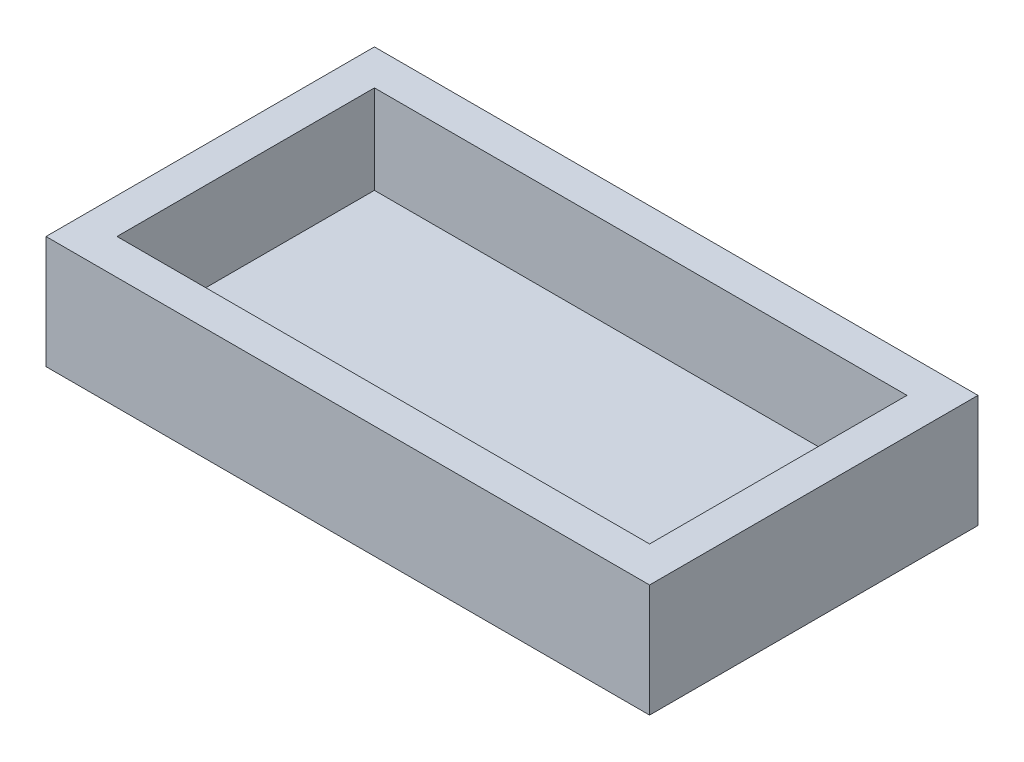
from build123d import *

# Parameters (mm, degrees)
SKETCH1_W           = 34
SKETCH1_H           = 18.5
SKETCH1_W_2         = 30
SKETCH1_H_2         = 14.5
BOSS_EXTRUDE1_DEPTH = 6.35
SKETCH2_W           = 30
SKETCH2_H           = 14.5
BOSS_EXTRUDE3_DEPTH = 1.35


with BuildPart() as part:
    # Sketch1 → Boss-Extrude1 (new body)
    with BuildSketch(Plane(origin=(0, 0, 0), x_dir=(1, 0, 0), z_dir=(0, 1, 0))):
        with Locations((15, 7.25)):
            Rectangle(SKETCH1_W, SKETCH1_H)
        with Locations((15, 7.25)):
            Rectangle(SKETCH1_W_2, SKETCH1_H_2, mode=Mode.SUBTRACT)
    extrude(amount=BOSS_EXTRUDE1_DEPTH)

    # Sketch2 → Boss-Extrude3 (add)
    with BuildSketch(Plane(origin=(0, 0, 0), x_dir=(1, 0, 0), z_dir=(0, 1, 0))):
        with Locations((15, 7.25)):
            Rectangle(SKETCH2_W, SKETCH2_H)
    extrude(amount=BOSS_EXTRUDE3_DEPTH)


solid = part.part
